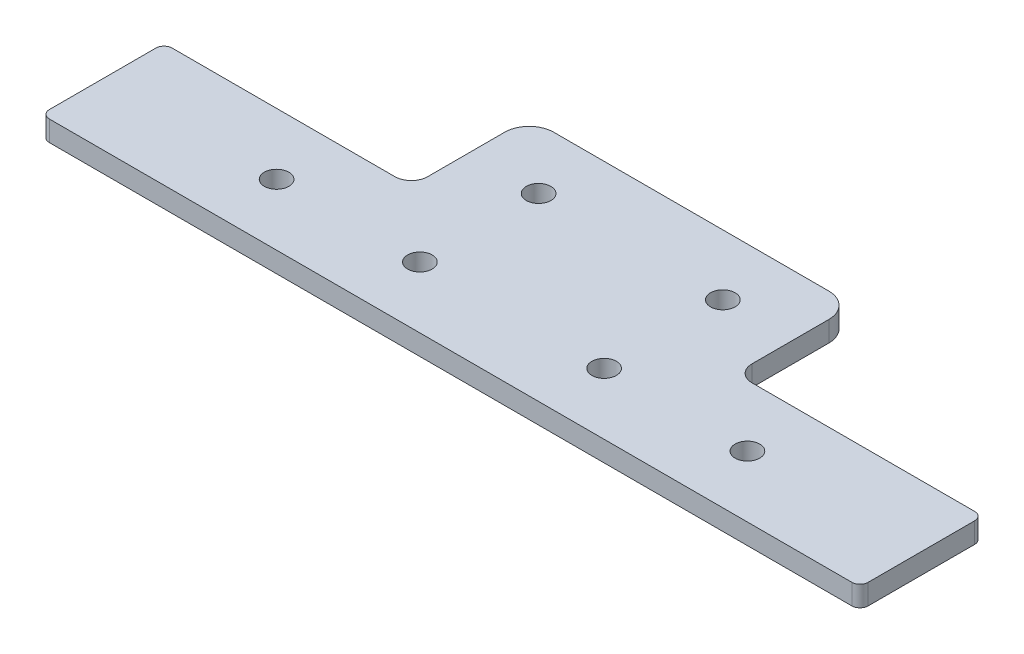
from build123d import *

# Parameters (mm, degrees)
SKETCH1_W           = 127
SKETCH1_H           = 19.05
BOSS_EXTRUDE1_DEPTH = 3.175
SKETCH3_W           = 50.292
SKETCH3_H           = 18.288
BOSS_EXTRUDE2_DEPTH = 3.175
SKETCH2_R           = 1.905
CUT_EXTRUDE1_DEPTH  = 4.175
FILLET1_R           = 1.27
FILLET2_R           = 2.54
FILLET3_R           = 3.81


with BuildPart() as part:
    # Sketch1 → Boss-Extrude1 (new body)
    with BuildSketch(Plane(origin=(0, 0, 0), x_dir=(1, 0, 0), z_dir=(0, 1, 0))):
        Rectangle(SKETCH1_W, SKETCH1_H)
    extrude(amount=BOSS_EXTRUDE1_DEPTH)

    # Sketch3 → Boss-Extrude2 (add, through all)
    with BuildSketch(Plane(origin=(0, 3.175, 0), x_dir=(1, 0, 0), z_dir=(0, 1, 0))):
        with Locations((0, 18.669)):
            Rectangle(SKETCH3_W, SKETCH3_H)
    extrude(amount=-BOSS_EXTRUDE2_DEPTH)

    # Sketch2 → Cut-Extrude1 (cut, through all)
    with BuildSketch(Plane(origin=(0, 3.175, 0), x_dir=(1, 0, 0), z_dir=(0, 1, 0))):
        with Locations((-36.5125, 0)):
            Circle(SKETCH2_R)
        with Locations((36.5125, 0)):
            Circle(SKETCH2_R)
        with Locations((-14.2875, 0)):
            Circle(SKETCH2_R)
        with Locations((14.2875, 0)):
            Circle(SKETCH2_R)
        with Locations((-14.2875, 18.415)):
            Circle(SKETCH2_R)
        with Locations((14.2875, 18.415)):
            Circle(SKETCH2_R)
    extrude(amount=-CUT_EXTRUDE1_DEPTH, mode=Mode.SUBTRACT)

    # Fillet1
    fillet1_edges = [part.edges().sort_by_distance(p)[0] for p in [
        (63.5, 1.5875, 9.525),
        (-63.5, 1.5875, 9.525),
        (-63.5, 1.5875, -9.525),
        (63.5, 1.5875, -9.525),
    ]]
    fillet(fillet1_edges, radius=FILLET1_R)

    # Fillet2
    fillet2_edges = [part.edges().sort_by_distance(p)[0] for p in [
        (-25.146, 1.5875, -9.525),
        (25.146, 1.5875, -9.525),
    ]]
    fillet(fillet2_edges, radius=FILLET2_R)

    # Fillet3
    fillet3_edges = [part.edges().sort_by_distance(p)[0] for p in [
        (-25.146, 1.5875, -27.813),
        (25.146, 1.5875, -27.813),
    ]]
    fillet(fillet3_edges, radius=FILLET3_R)


solid = part.part
